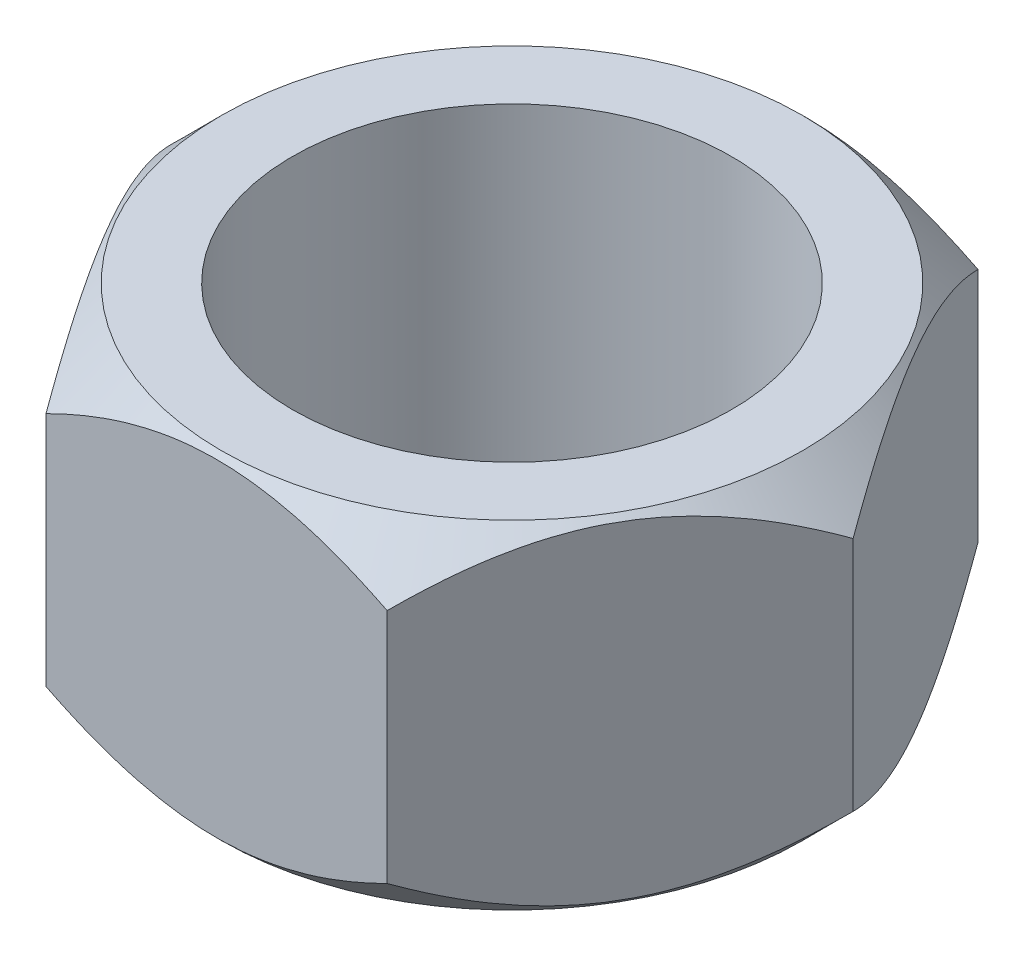
from build123d import *

# Parameters (mm, degrees)
BOSS_EXTRUDE1_DEPTH = 0.2
CUT_EXTRUDE2_REACH  = 2.2
SKETCH4_R           = 0.13


with BuildPart() as part:
    # Sketch2 → Boss-Extrude1 (new body)
    with BuildSketch(Plane(origin=(0, 0, 0), x_dir=(1, 0, 0), z_dir=(0, 1, 0))):
        Polygon((0.202072594, 0), (0.101036297, 0.175), (-0.101036297, 0.175), (-0.202072594, 0), (-0.101036297, -0.175), (0.101036297, -0.175), align=None)
    extrude(amount=BOSS_EXTRUDE1_DEPTH)

    # Sketch4 → Cut-Extrude2 (cut, up to next)
    with BuildSketch(Plane(origin=(0, 0.2, 0), x_dir=(1, 0, 0), z_dir=(0, 1, 0)), mode=Mode.PRIVATE) as cut_extrude2_sk1:
        Circle(SKETCH4_R)
    cut_extrude2_tool1 = extrude(cut_extrude2_sk1.sketch, amount=-CUT_EXTRUDE2_REACH, mode=Mode.PRIVATE) & part.part
    add(cut_extrude2_tool1.solids().sort_by_distance((0, 0.2, 0))[0], mode=Mode.SUBTRACT)

    # Sketch5 → Cut-Revolve1 (revolve, cut)
    with BuildSketch(Plane.XY):
        Polygon((0.202072594, 0), (0.172072594, 0), (0.202072594, 0.03), align=None)
        Polygon((0.202072594, 0.17), (0.202072594, 0.2), (0.172072594, 0.2), align=None)
    revolve(axis=Axis((0, 0, 0), (0, 1, 0)), mode=Mode.SUBTRACT)


solid = part.part
